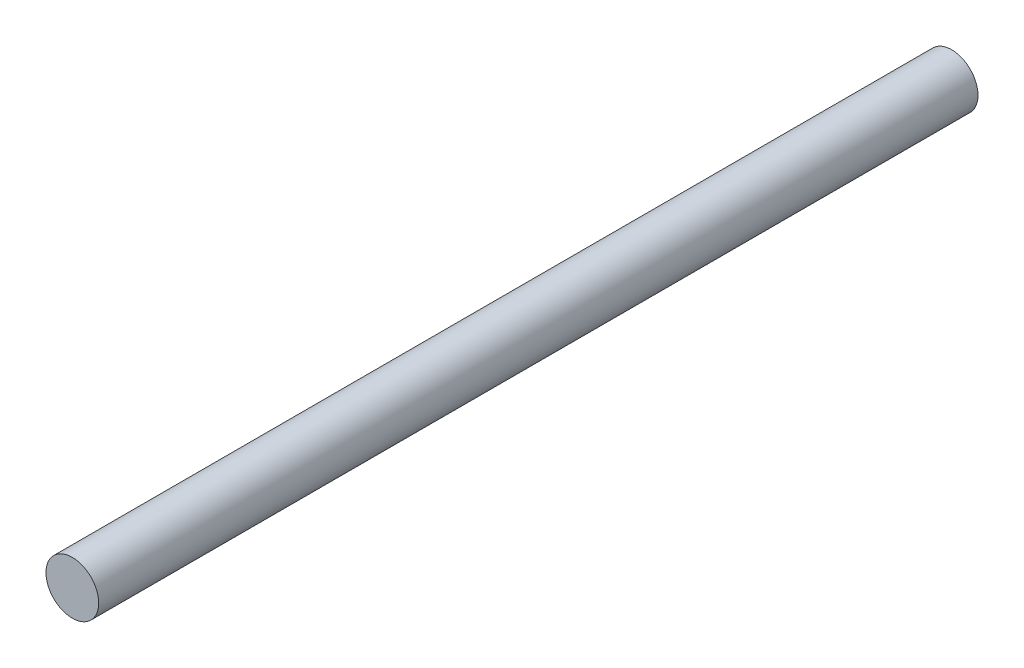
from build123d import *

# Parameters (mm, degrees)
ESQUISSE1_R        = 1.5
BOSS_EXTRU_1_DEPTH = 50


with BuildPart() as part:
    # Esquisse1 → Boss.-Extru.1 (new body)
    with BuildSketch(Plane.XY):
        Circle(ESQUISSE1_R)
    extrude(amount=BOSS_EXTRU_1_DEPTH)


solid = part.part
